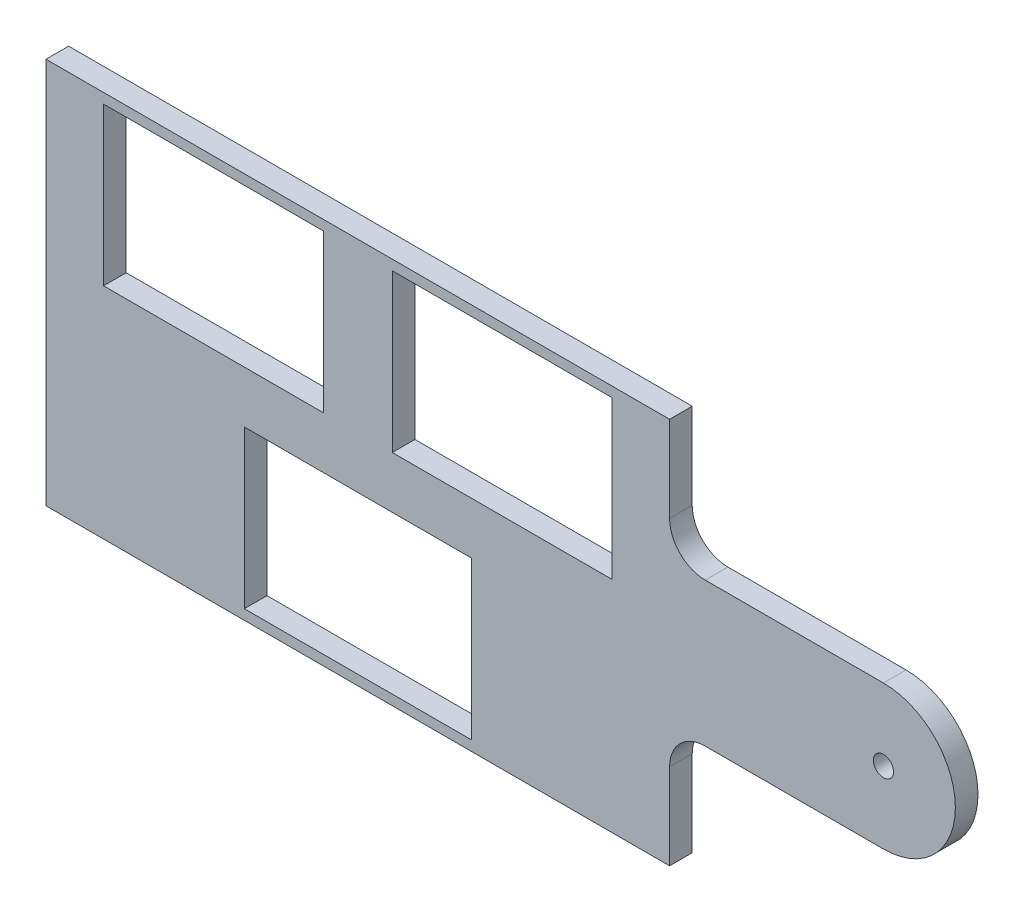
from build123d import *

# Parameters (mm, degrees)
SKETCH1_W           = 87.47
SKETCH1_H           = 60.6
BOSS_EXTRUDE1_DEPTH = 3.175
BOSS_EXTRUDE2_DEPTH = 3.175
FILLET1_R           = 5
SKETCH5_R           = 1.415
CUT_EXTRUDE2_DEPTH  = 10
SKETCH6_W           = 87.47
SKETCH6_H           = 3.265
CUT_EXTRUDE3_DEPTH  = 10
SKETCH2_W           = 30.83
SKETCH2_H           = 22.08
SKETCH2_W_2         = 31.83
CUT_EXTRUDE4_DEPTH  = 10
SKETCH8_W           = 87.47
SKETCH8_H           = 0.09
BOSS_EXTRUDE3_DEPTH = 3.175


with BuildPart() as part:
    # Sketch1 → Boss-Extrude1 (new body)
    with BuildSketch(Plane.XY):
        Rectangle(SKETCH1_W, SKETCH1_H)
    extrude(amount=BOSS_EXTRUDE1_DEPTH)

    # Sketch3 → Boss-Extrude2 (add)
    with BuildSketch(Plane.XY.offset(3.175)):
        with BuildLine():
            Line((43.735, 10.085), (43.735, -10.085))
            Line((43.735, -10.085), (73.735, -10.085))
            ThreePointArc((73.735, -10.085), (83.82, 0), (73.735, 10.085))
            Line((73.735, 10.085), (43.735, 10.085))
        make_face()
    extrude(amount=-BOSS_EXTRUDE2_DEPTH)

    # Fillet1
    fillet1_edges = [part.edges().sort_by_distance(p)[0] for p in [
        (43.735, -10.085, 1.5875),
        (43.735, 10.085, 1.5875),
    ]]
    fillet(fillet1_edges, radius=FILLET1_R)

    # Sketch5 → Cut-Extrude2 (cut)
    with BuildSketch(Plane.XY.offset(3.175)):
        with Locations((73.735, 0)):
            Circle(SKETCH5_R)
    extrude(amount=-CUT_EXTRUDE2_DEPTH, mode=Mode.SUBTRACT)

    # Sketch6 → Cut-Extrude3 (cut)
    with BuildSketch(Plane.XY.offset(3.175)):
        with Locations((0, 28.6675)):
            Rectangle(SKETCH6_W, SKETCH6_H)
        with Locations((0, -28.6675)):
            Rectangle(SKETCH6_W, SKETCH6_H)
    extrude(amount=-CUT_EXTRUDE3_DEPTH, mode=Mode.SUBTRACT)

    # Sketch2 → Cut-Extrude4 (cut)
    with BuildSketch(Plane.XY.offset(3.175)):
        with Locations((20.25, 14.675)):
            Rectangle(SKETCH2_W, SKETCH2_H)
        with Locations((-20.25, 14.675)):
            Rectangle(SKETCH2_W, SKETCH2_H)
        with Locations((0, -14.675)):
            Rectangle(SKETCH2_W_2, SKETCH2_H)
    extrude(amount=-CUT_EXTRUDE4_DEPTH, mode=Mode.SUBTRACT)

    # Sketch8 → Boss-Extrude3 (add)
    with BuildSketch(Plane.XY.offset(3.175)):
        with Locations((0, 27.08)):
            Rectangle(SKETCH8_W, SKETCH8_H)
        with Locations((0, -27.08)):
            Rectangle(SKETCH8_W, SKETCH8_H)
    extrude(amount=-BOSS_EXTRUDE3_DEPTH)


solid = part.part
